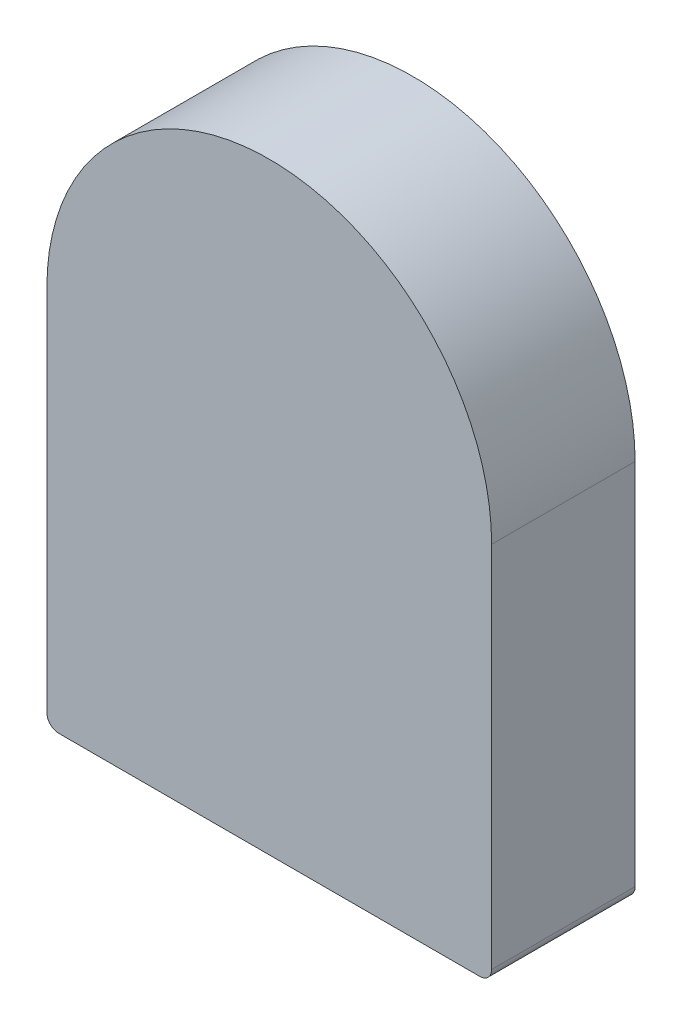
from build123d import *

# Parameters (mm, degrees)
EXTRUDE_1_DEPTH = 6
FILLET_1_R      = 0.5


with BuildPart() as part:
    # 草图1 → 凸台-拉伸1 (new body)
    with BuildSketch(Plane.XY):
        with BuildLine():
            Line((-9.3, 0), (-9.3, -15.9))
            Line((-9.3, -15.9), (9.3, -15.9))
            Line((9.3, -15.9), (9.3, 0))
            ThreePointArc((9.3, 0), (0, 9.3), (-9.3, 0))
        make_face()
    extrude(amount=EXTRUDE_1_DEPTH)

    # 圆角1
    fillet_1_edges = [part.edges().sort_by_distance(p)[0] for p in [
        (9.3, -15.9, 3),
        (-9.3, -15.9, 3),
    ]]
    fillet(fillet_1_edges, radius=FILLET_1_R)


solid = part.part
